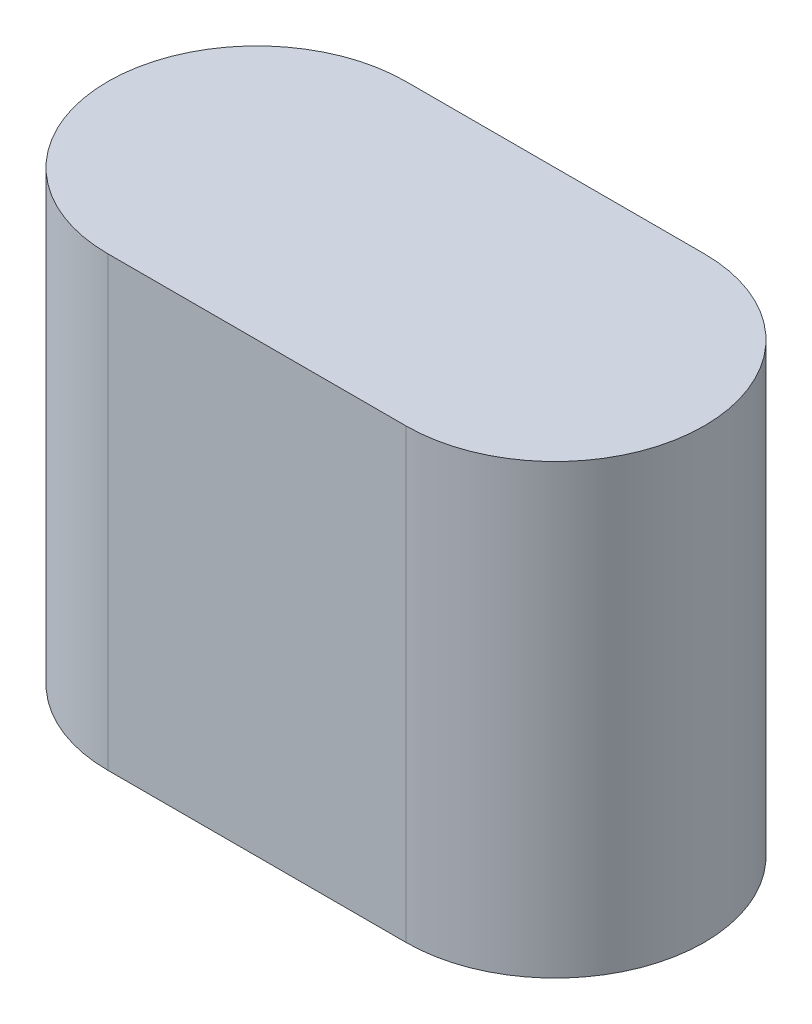
from build123d import *

# Parameters (mm, degrees)
EXTRUDE1_DEPTH = 7.62


with BuildPart() as part:
    # Sketch1 → Extrude1 (new body)
    with BuildSketch(Plane(origin=(0, 0, 0), x_dir=(1, 0, 0), z_dir=(0, 1, 0))):
        with BuildLine():
            Line((-2.54, 2.54), (2.54, 2.54))
            ThreePointArc((2.54, 2.54), (5.08, 0), (2.54, -2.54))
            Line((2.54, -2.54), (-2.54, -2.54))
            ThreePointArc((-2.54, -2.54), (-5.08, 0), (-2.54, 2.54))
        make_face()
    extrude(amount=EXTRUDE1_DEPTH)


solid = part.part
